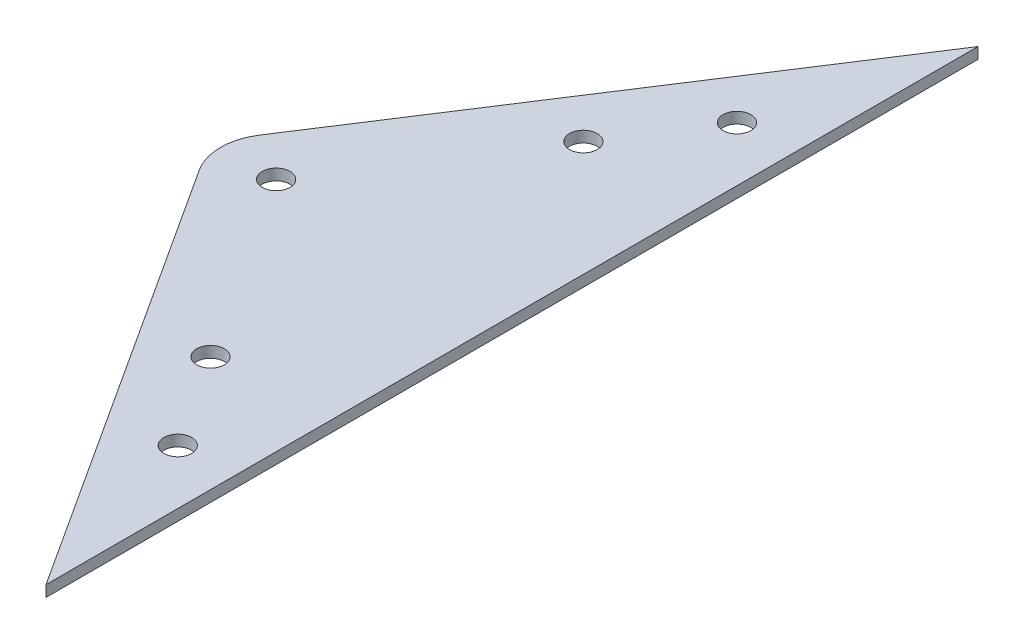
from build123d import *

# Parameters (mm, degrees)
SKETCH1_R           = 2.5
BOSS_EXTRUDE1_DEPTH = 2


with BuildPart() as part:
    # Sketch1 → Boss-Extrude1 (new body)
    with BuildSketch(Plane(origin=(0, 0, 0), x_dir=(1, 0, 0), z_dir=(0, 1, 0))):
        with BuildLine():
            Line((63.73099869, -373.254460076), (114.596265016, -294.778975996))
            Line((114.596265016, -294.778975996), (114.596265016, -462.608083148))
            Line((114.596265016, -462.608083148), (63.73099869, -384.132599068))
            ThreePointArc((63.73099869, -384.132599068), (62.122454047, -378.693529572), (63.73099869, -373.254460076))
        make_face()
        with Locations((72.122454047, -378.693529572)):
            Circle(SKETCH1_R, mode=Mode.SUBTRACT)
        with Locations((93.878732031, -345.127708141)):
            Circle(SKETCH1_R, mode=Mode.SUBTRACT)
        with Locations((104.756871022, -328.344797426)):
            Circle(SKETCH1_R, mode=Mode.SUBTRACT)
        with Locations((93.878732031, -412.259351002)):
            Circle(SKETCH1_R, mode=Mode.SUBTRACT)
        with Locations((104.756871022, -429.042261718)):
            Circle(SKETCH1_R, mode=Mode.SUBTRACT)
    extrude(amount=BOSS_EXTRUDE1_DEPTH)


solid = part.part
